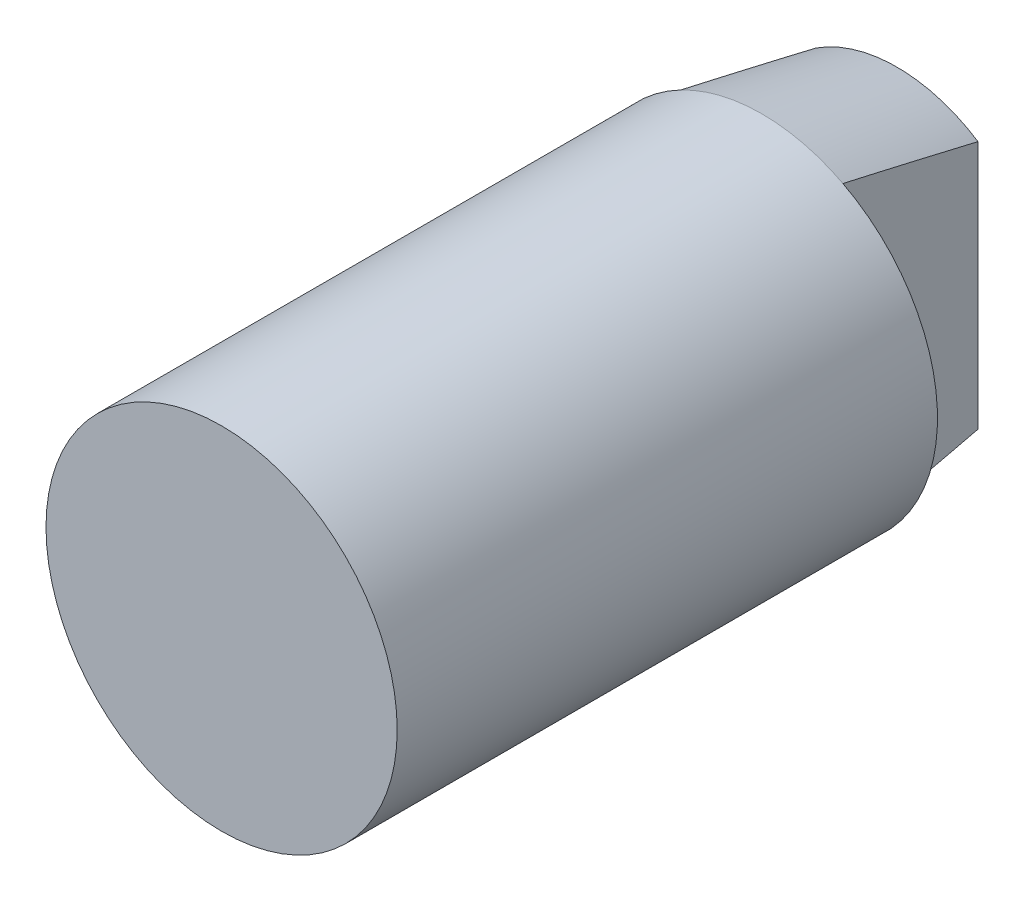
from build123d import *

# Parameters (mm, degrees)
CUT_EXTRUDE1_DEPTH = 5
SKETCH3_W          = 6
SKETCH3_H          = 5
CUT_EXTRUDE2_DEPTH = 12


with BuildPart() as part:
    # Sketch1 → Revolve1 (revolve)
    with BuildSketch(Plane(origin=(0, 0, 0), x_dir=(0, 0, -1), z_dir=(1, 0, 0))):
        Polygon((0, 0), (0, 6.5), (20, 6.5), (25, 5.5), (25, 0), align=None)
    revolve(axis=Axis((0, 0, -25), (0, 0, 1)))

    # Sketch2 → Cut-Extrude1 (cut)
    with BuildSketch(Plane(origin=(0, 0, -25), x_dir=(-1, 0, 0), z_dir=(0, 0, -1))):
        with BuildLine():
            Line((-3, 5.766281297), (-3, -5.766281297))
            ThreePointArc((-3, -5.766281297), (-6.5, 0), (-3, 5.766281297))
        make_face()
        with BuildLine():
            Line((3, 5.766281297), (3, -5.766281297))
            ThreePointArc((3, -5.766281297), (6.5, 0), (3, 5.766281297))
        make_face()
    extrude(amount=-CUT_EXTRUDE1_DEPTH, mode=Mode.SUBTRACT)

    # Sketch3 → Cut-Extrude2 (cut)
    with BuildSketch(Plane(origin=(0, 0, -20), x_dir=(-1, 0, 0), z_dir=(0, 0, -1))):
        with Locations((6.5, 0)):
            Rectangle(SKETCH3_W, SKETCH3_H)
    extrude(amount=-CUT_EXTRUDE2_DEPTH, mode=Mode.SUBTRACT)


solid = part.part
